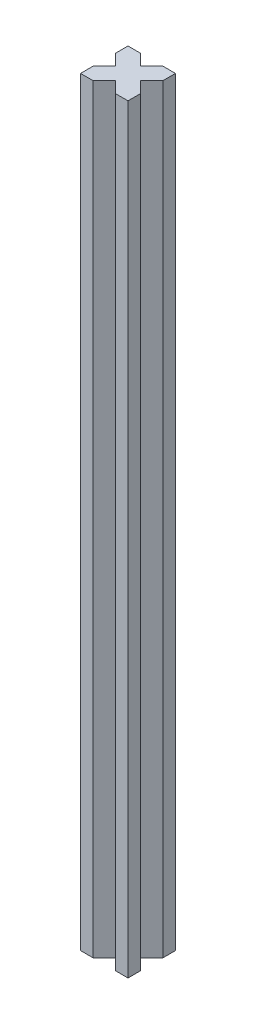
from build123d import *

# Parameters (mm, degrees)
BOSS_EXTRUDE1_DEPTH = 240


with BuildPart() as part:
    # Sketch1 → Boss-Extrude1 (new body)
    with BuildSketch(Plane(origin=(0, 0, 0), x_dir=(1, 0, 0), z_dir=(0, 1, 0))):
        Polygon((0, 0), (4, 0), (7.5, 3.5), (11, 0), (15, 0), (15, 4), (11.5, 7.5), (15, 11), (15, 15), (11, 15), (7.5, 11.5), (4, 15), (0, 15), (0, 11), (3.5, 7.5), (0, 4), align=None)
    extrude(amount=BOSS_EXTRUDE1_DEPTH)


solid = part.part
